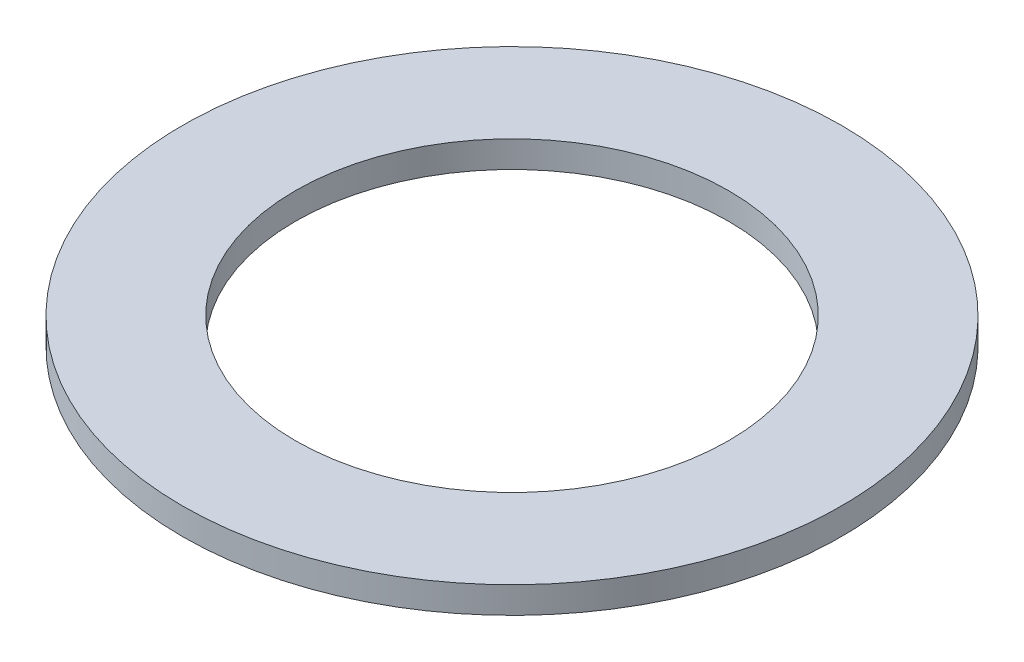
from build123d import *

# Parameters (mm, degrees)
SKETCH1_R           = 12.4
SKETCH1_R_2         = 8.15
BOSS_EXTRUDE1_DEPTH = 1


with BuildPart() as part:
    # Sketch1 → Boss-Extrude1 (new body)
    with BuildSketch(Plane(origin=(0, 0, 0), x_dir=(1, 0, 0), z_dir=(0, 1, 0))):
        Circle(SKETCH1_R)
        Circle(SKETCH1_R_2, mode=Mode.SUBTRACT)
    extrude(amount=BOSS_EXTRUDE1_DEPTH)


solid = part.part
